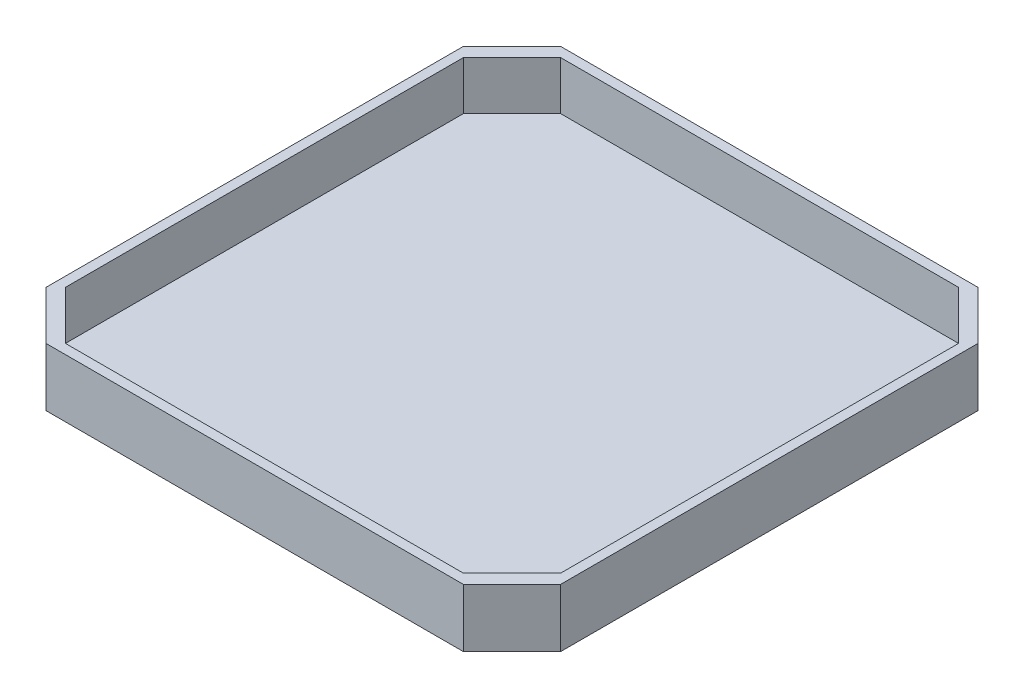
from build123d import *

# Parameters (mm, degrees)
SKETCH1_W           = 106
SKETCH1_H           = 106
BOSS_EXTRUDE1_DEPTH = 2
SKETCH2_W           = 106
SKETCH2_H           = 106
SKETCH2_W_2         = 102
SKETCH2_H_2         = 102
BOSS_EXTRUDE2_DEPTH = 10
CHAMFER1_SIZE       = 10


with BuildPart() as part:
    # Sketch1 → Boss-Extrude1 (new body)
    with BuildSketch(Plane(origin=(0, 0, 0), x_dir=(1, 0, 0), z_dir=(0, 1, 0))):
        Rectangle(SKETCH1_W, SKETCH1_H)
    extrude(amount=BOSS_EXTRUDE1_DEPTH)

    # Sketch2 → Boss-Extrude2 (add)
    with BuildSketch(Plane(origin=(0, 2, 0), x_dir=(1, 0, 0), z_dir=(0, 1, 0))):
        Rectangle(SKETCH2_W, SKETCH2_H)
        Rectangle(SKETCH2_W_2, SKETCH2_H_2, mode=Mode.SUBTRACT)
    extrude(amount=BOSS_EXTRUDE2_DEPTH)

    # Chamfer1
    chamfer1_edges = [part.edges().sort_by_distance(p)[0] for p in [
        (-51, 7, -51),
        (-51, 7, 51),
        (51, 7, 51),
        (51, 7, -51),
        (-53, 6, -53),
        (53, 6, -53),
        (53, 6, 53),
        (-53, 6, 53),
    ]]
    chamfer(chamfer1_edges, length=CHAMFER1_SIZE)


solid = part.part
